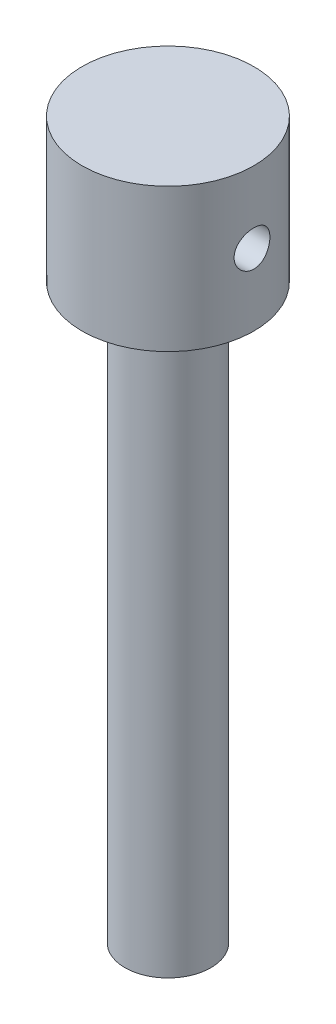
from build123d import *

# Parameters (mm, degrees)
SKETCH1_R               = 152.4
BOSS_EXTRUDE1_DEPTH     = 2540
SKETCH1_3_R             = 304.8
SKETCH1_3_R_2           = 152.4
BOSS_EXTRUDE2_DEPTH     = 508
CUT_EXTRUDE1_DEPTH      = 2577.316378087
CUT_EXTRUDE1_DEPTH_BACK = 2577.316378087
SKETCH2_R               = 63.5


with BuildPart() as part:
    # Sketch1 → Boss-Extrude1 (new body)
    with BuildSketch(Plane(origin=(0, 0, 0), x_dir=(1, 0, 0), z_dir=(0, 1, 0))):
        Circle(SKETCH1_R)
    extrude(amount=-BOSS_EXTRUDE1_DEPTH)

    # Sketch1_3 → Boss-Extrude2 (add)
    with BuildSketch(Plane(origin=(0, 0, 0), x_dir=(1, 0, 0), z_dir=(0, 1, 0))):
        Circle(SKETCH1_3_R)
        Circle(SKETCH1_3_R_2, mode=Mode.SUBTRACT)
    extrude(amount=-BOSS_EXTRUDE2_DEPTH)

    # Sketch2 → Cut-Extrude1 (cut, two sides: drawn at the far end of the back side and taken through both)
    with BuildSketch(Plane(origin=(0, 0, 0), x_dir=(0, 0, -1), z_dir=(1, 0, 0)).offset(-CUT_EXTRUDE1_DEPTH_BACK)):
        with Locations((0, -254)):
            Circle(SKETCH2_R)
    extrude(amount=CUT_EXTRUDE1_DEPTH + CUT_EXTRUDE1_DEPTH_BACK, mode=Mode.SUBTRACT)


solid = part.part
